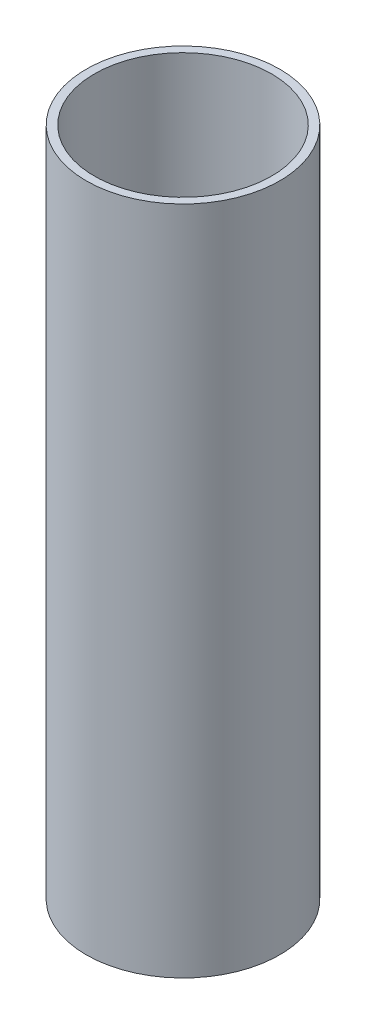
from build123d import *

# Parameters (mm, degrees)
CROQUIS1_W = 1.95
CROQUIS1_H = 160


with BuildPart() as part:
    # Croquis1 → Revolución1 (revolve)
    with BuildSketch(Plane(origin=(0, 0, 0), x_dir=(0, 0, -1), z_dir=(1, 0, 0))):
        with Locations((22.125, 80)):
            Rectangle(CROQUIS1_W, CROQUIS1_H)
    revolve(axis=Axis((0, 0, 0), (0, 1, 0)))


solid = part.part
